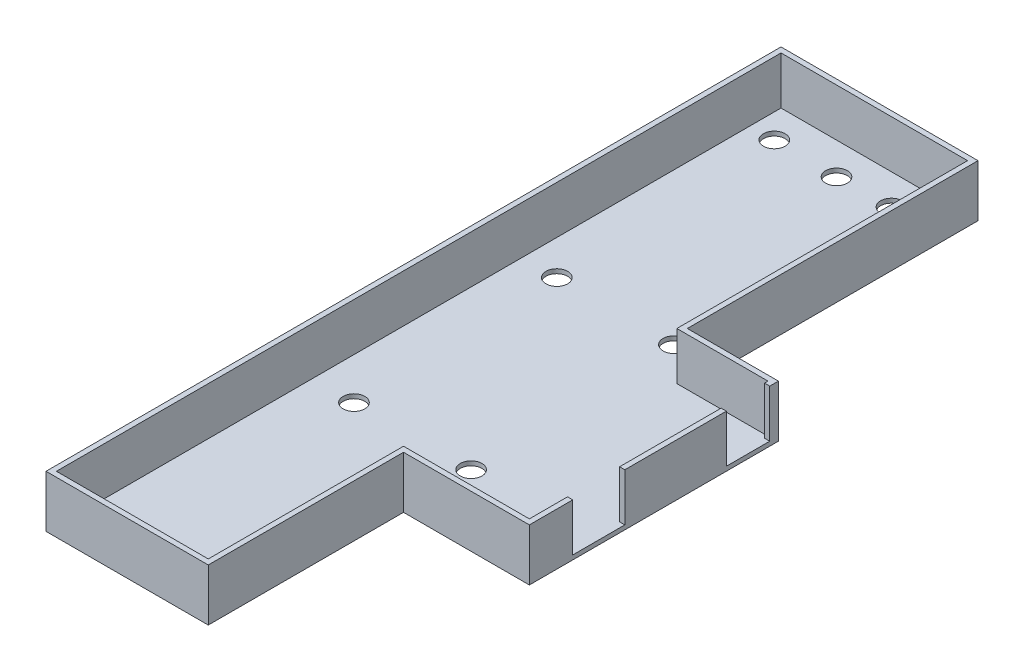
from build123d import *

# Parameters (mm, degrees)
BOSS_EXTRUDE1_DEPTH = 1
BOSS_EXTRUDE2_DEPTH = 12
SKETCH2_W           = 10
SKETCH2_H           = 11
SKETCH2_W_2         = 12
CUT_EXTRUDE1_DEPTH  = 12
SKETCH3_R           = 2.5
CUT_EXTRUDE2_DEPTH  = 12


with BuildPart() as part:
    # Sketch1 → Boss-Extrude1 (new body)
    with BuildSketch(Plane(origin=(0, 0, 0), x_dir=(1, 0, 0), z_dir=(0, 1, 0))):
        Polygon((-1.2, 1.2), (44.2, 1.2), (44.2, -65.8), (65.2, -65.8), (65.2, -123.2), (36.2, -123.2), (36.2, -168.2), (-1.2, -168.2), align=None)
        Polygon((0, -167), (35, -167), (35, -122), (64, -122), (64, -67), (43, -67), (43, 0), (0, 0), align=None, mode=Mode.SUBTRACT)
        Polygon((0, 0), (0, -167), (35, -167), (35, -122), (64, -122), (64, -67), (43, -67), (43, 0), align=None)
    extrude(amount=BOSS_EXTRUDE1_DEPTH)

    # Sketch1_3 → Boss-Extrude2 (add)
    with BuildSketch(Plane(origin=(0, 0, 0), x_dir=(1, 0, 0), z_dir=(0, 1, 0))):
        Polygon((-1.2, 1.2), (-1.2, -168.2), (36.2, -168.2), (36.2, -123.2), (65.2, -123.2), (65.2, -65.8), (44.2, -65.8), (44.2, 1.2), align=None)
        Polygon((0, 0), (0, -167), (35, -167), (35, -122), (64, -122), (64, -67), (43, -67), (43, 0), align=None, mode=Mode.SUBTRACT)
    extrude(amount=BOSS_EXTRUDE2_DEPTH)

    # Sketch2 → Cut-Extrude1 (cut)
    with BuildSketch(Plane(origin=(65.2, 0, 0), x_dir=(0, 0, -1), z_dir=(1, 0, 0))):
        with Locations((-72.8, 6.5)):
            Rectangle(SKETCH2_W, SKETCH2_H)
        with Locations((-107.2, 6.5)):
            Rectangle(SKETCH2_W_2, SKETCH2_H)
    extrude(amount=-CUT_EXTRUDE1_DEPTH, mode=Mode.SUBTRACT)

    # Sketch3 → Cut-Extrude2 (cut)
    with BuildSketch(Plane(origin=(0, 1, 0), x_dir=(1, 0, 0), z_dir=(0, 1, 0))):
        with Locations(Location((5.592629817, -7.1408635, 0), (0, 0, 270))):
            Circle(SKETCH3_R)
        with Locations(Location((20.139491033, -7.350170855, 0), (0, 0, 270))):
            Circle(SKETCH3_R)
        with Locations(Location((32.488625014, -7.036209822, 0), (0, 0, 270))):
            Circle(SKETCH3_R)
        with Locations(Location((7.999664407, -59.67700976, 0), (0, 0, 270))):
            Circle(SKETCH3_R)
        with Locations(Location((34.895659604, -59.572356082, 0), (0, 0, 270))):
            Circle(SKETCH3_R)
        with Locations(Location((9.579399834, -108.003673304, 0), (0, 0, 270))):
            Circle(SKETCH3_R)
        with Locations(Location((36.475395031, -107.899019626, 0), (0, 0, 270))):
            Circle(SKETCH3_R)
        with Locations(Location((4.511546122, -160.279750326, 0), (0, 0, 270))):
            Circle(SKETCH3_R)
        with Locations(Location((31.407541319, -160.175096649, 0), (0, 0, 270))):
            Circle(SKETCH3_R)
    extrude(amount=-CUT_EXTRUDE2_DEPTH, mode=Mode.SUBTRACT)


solid = part.part
